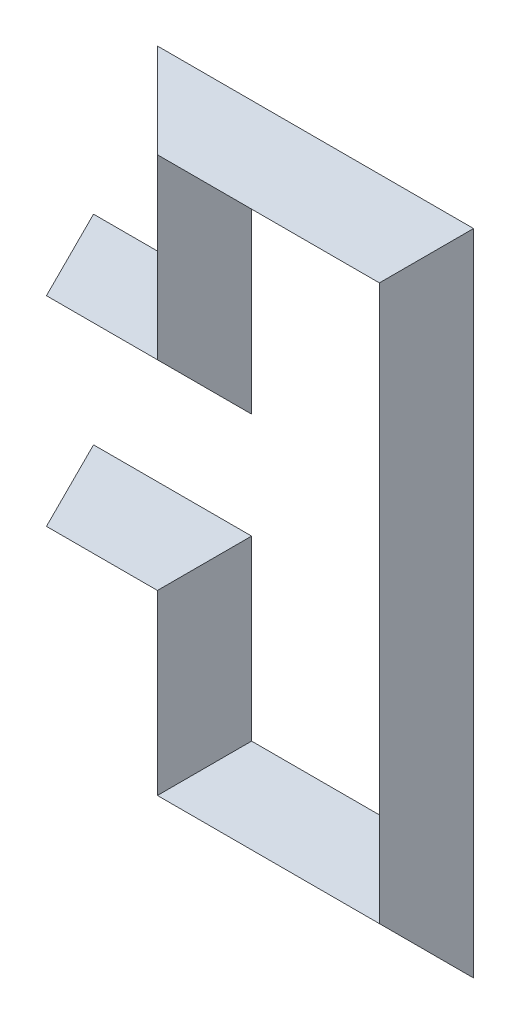
from build123d import *


with BuildPart() as part:
    # 스윕1: sweep along a path in 스케치2
    with BuildLine(Plane.XY) as sweep_1_path:
        Line((0, 0), (50, 0))
        Line((50, 0), (50, 80))
        Line((50, 80), (150, 80))
        Line((150, 80), (150, -170))
        Line((150, -170), (50, -170))
        Line((50, -170), (50, -90))
        Line((50, -90), (0, -90))
    # 스케치3 → 스윕1 (sweep)
    with BuildSketch(Plane(origin=(0, 0, 0), x_dir=(0, 0, -1), z_dir=(1, 0, 0))):
        Polygon((21.213203436, 0), (0, -21.213203436), (-21.213203436, 0), (0, 21.213203436), align=None)
    sweep(path=sweep_1_path.line, transition=Transition.RIGHT)


solid = part.part
